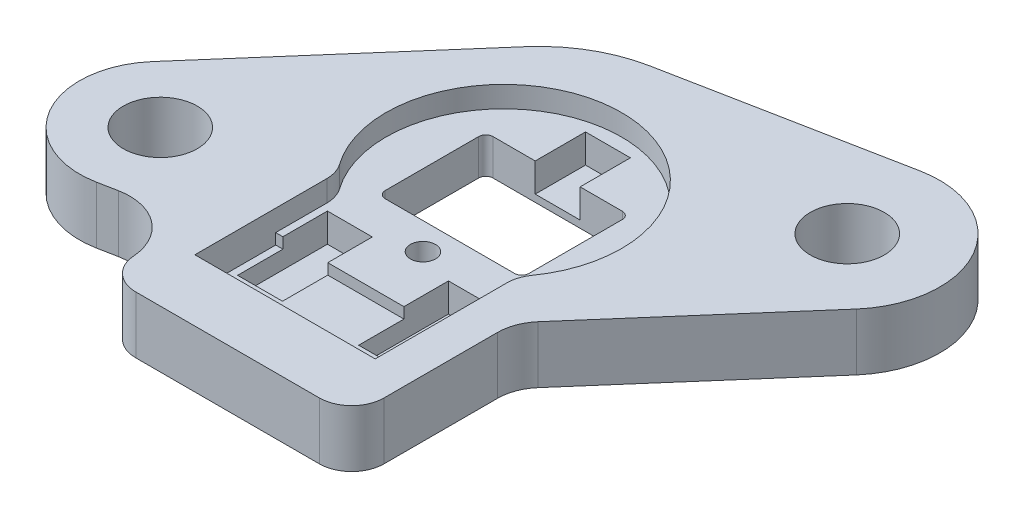
from build123d import *

# Parameters (mm, degrees)
BOSS_EXTRUDE1_DEPTH            = 4.0386
SKETCH2_R                      = 4.7625
BOSS_EXTRUDE2_DEPTH            = 0.508
SKETCH3_R                      = 4.7625
BOSS_EXTRUDE3_DEPTH            = 0.508
CUT_EXTRUDE1_DEPTH             = 1.4986
SKETCH5_W                      = 12.7508
SKETCH5_H                      = 5.715
CUT_EXTRUDE2_DEPTH             = 0.762
SKETCH6_W                      = 3.175
SKETCH6_H                      = 3.2004
CUT_EXTRUDE3_DEPTH             = 1.27
SKETCH7_W                      = 3.175
SKETCH7_H                      = 3.2004
CUT_EXTRUDE4_DEPTH             = 1.27
SKETCH8_W                      = 3.175
SKETCH8_H                      = 2.032
CUT_EXTRUDE5_DEPTH             = 3.1496
SKETCH9_W                      = 3.175
SKETCH9_H                      = 2.032
CUT_EXTRUDE6_DEPTH             = 3.1496
SKETCH10_W                     = 10.16
SKETCH10_H                     = 7.62
CUT_EXTRUDE7_DEPTH             = 5.0386
SKETCH11_W                     = 3.175
SKETCH11_H                     = 2.032
CUT_EXTRUDE8_DEPTH             = 3.556
F_10_CLEARANCE_HOLE1_D         = 5.2324
F_10_CLEARANCE_HOLE1_DEPTH     = 4.5466
F_50_0_07_DIAMETER_HOLE1_D     = 1.778
F_50_0_07_DIAMETER_HOLE1_DEPTH = 3.048
FILLET1_R                      = 0.508
FILLET3_R                      = 2.286
FILLET4_R                      = 3.175
FILLET5_R                      = 9.9187


with BuildPart() as part:
    # Sketch1 → Boss-Extrude1 (new body)
    with BuildSketch(Plane(origin=(0, 2.0193, 0), x_dir=(1, 0, 0), z_dir=(0, 1, 0))):
        with BuildLine():
            Line((-8.93437079, -19.83232), (9.077817244, -19.83232))
            Line((9.077817244, -19.83232), (9.077817244, -8.327843243))
            Line((9.077817244, -8.327843243), (20.330239386, 4.595371256))
            ThreePointArc((20.330239386, 4.595371256), (21.061730892, 12.159996), (14.144827941, 15.308818145))
            Line((14.144827941, 15.308818145), (-5.192523198, 11.533713998))
            Line((-5.192523198, 11.533713998), (-19.708049879, -5.137120292))
            ThreePointArc((-19.708049879, -5.137120292), (-20.347266862, -11.7475), (-14.302901614, -14.499111708))
            Line((-14.302901614, -14.499111708), (-12.995647781, -14.243905122))
            ThreePointArc((-12.995647781, -14.243905122), (-9.183549937, -15.74346998), (-8.93437079, -19.83232))
        make_face()
    extrude(amount=-BOSS_EXTRUDE1_DEPTH)

    # Sketch2 → Boss-Extrude2 (add)
    with BuildSketch(Plane.XZ.offset(2.0193)):
        with Locations((15.397931679, -8.89)):
            Circle(SKETCH2_R)
    extrude(amount=BOSS_EXTRUDE2_DEPTH)

    # Sketch3 → Boss-Extrude3 (add)
    with BuildSketch(Plane.XZ.offset(2.0193)):
        with Locations((-15.397931679, 8.89)):
            Circle(SKETCH3_R)
    extrude(amount=BOSS_EXTRUDE3_DEPTH)

    # Sketch4 → Cut-Extrude1 (cut)
    with BuildSketch(Plane(origin=(0, 2.0193, 0), x_dir=(-1, 0, 0), z_dir=(0, 1, 0))):
        with BuildLine():
            Line((6.3754, 5.363130455), (6.3754, 15.4686))
            Line((6.3754, 15.4686), (-6.3754, 15.4686))
            Line((-6.3754, 15.4686), (-6.3754, 5.363130455))
            ThreePointArc((-6.3754, 5.363130455), (0, -8.3312), (6.3754, 5.363130455))
        make_face()
    extrude(amount=-CUT_EXTRUDE1_DEPTH, mode=Mode.SUBTRACT)

    # Sketch5 → Cut-Extrude2 (cut)
    with BuildSketch(Plane(origin=(0, 0.5207, 0), x_dir=(-1, 0, 0), z_dir=(0, 1, 0))):
        with Locations((0, 12.6111)):
            Rectangle(SKETCH5_W, SKETCH5_H)
    extrude(amount=-CUT_EXTRUDE2_DEPTH, mode=Mode.SUBTRACT)

    # Sketch6 → Cut-Extrude3 (cut)
    with BuildSketch(Plane(origin=(0, -0.2413, 0), x_dir=(-1, 0, 0), z_dir=(0, 1, 0))):
        with Locations((4.2799, 11.3538)):
            Rectangle(SKETCH6_W, SKETCH6_H)
    extrude(amount=-CUT_EXTRUDE3_DEPTH, mode=Mode.SUBTRACT)

    # Sketch7 → Cut-Extrude4 (cut)
    with BuildSketch(Plane(origin=(0, -0.2413, 0), x_dir=(-1, 0, 0), z_dir=(0, 1, 0))):
        with Locations((-4.2799, 11.3538)):
            Rectangle(SKETCH7_W, SKETCH7_H)
    extrude(amount=-CUT_EXTRUDE4_DEPTH, mode=Mode.SUBTRACT)

    # Sketch8 → Cut-Extrude5 (cut)
    with BuildSketch(Plane.XY.offset(9.7536)):
        with Locations((4.2799, -0.4953)):
            Rectangle(SKETCH8_W, SKETCH8_H)
    extrude(amount=-CUT_EXTRUDE5_DEPTH, mode=Mode.SUBTRACT)

    # Sketch9 → Cut-Extrude6 (cut)
    with BuildSketch(Plane.XY.offset(9.7536)):
        with Locations((-4.2799, -0.4953)):
            Rectangle(SKETCH9_W, SKETCH9_H)
    extrude(amount=-CUT_EXTRUDE6_DEPTH, mode=Mode.SUBTRACT)

    # Sketch10 → Cut-Extrude7 (cut, through all)
    with BuildSketch(Plane.XZ.offset(2.0193)):
        Rectangle(SKETCH10_W, SKETCH10_H)
    extrude(amount=-CUT_EXTRUDE7_DEPTH, mode=Mode.SUBTRACT)

    # Sketch11 → Cut-Extrude8 (cut)
    with BuildSketch(Plane.XY.offset(-3.81)):
        with Locations((0, -0.4953)):
            Rectangle(SKETCH11_W, SKETCH11_H)
    extrude(amount=-CUT_EXTRUDE8_DEPTH, mode=Mode.SUBTRACT)

    # #10 Clearance Hole1
    with Locations(Plane(origin=(0, -2.5273, 0), x_dir=(-1, 0, 0), z_dir=(0, -1, 0))):
        with Locations((15.397931679, -8.89), (-15.397931679, 8.89)):
            Hole(F_10_CLEARANCE_HOLE1_D / 2, depth=F_10_CLEARANCE_HOLE1_DEPTH)

    # #50 (0.07) Diameter Hole1
    with Locations(Plane(origin=(0, 0.5207, 0), x_dir=(1, 0, 0), z_dir=(0, 1, 0))):
        with Locations((0, -5.715)):
            Hole(F_50_0_07_DIAMETER_HOLE1_D / 2, depth=F_50_0_07_DIAMETER_HOLE1_DEPTH)

    # Fillet1
    fillet1_edges = [part.edges().sort_by_distance(p)[0] for p in [
        (-5.08, -0.7493, 3.81),
        (5.08, -0.7493, 3.81),
        (5.08, -0.7493, -3.81),
        (-5.08, -0.7493, -3.81),
    ]]
    fillet(fillet1_edges, radius=FILLET1_R)

    # Fillet3
    fillet3_edges = [part.edges().sort_by_distance(p)[0] for p in [
        (9.077817244, 0, 19.83232),
        (-8.93437079, 0, 19.83232),
        (-6.3754, 1.27, 5.363130455),
        (6.3754, 1.27, 5.363130455),
    ]]
    fillet(fillet3_edges, radius=FILLET3_R)

    # Fillet4
    fillet4_edges = [part.edges().sort_by_distance(p)[0] for p in [
        (9.077817244, 0, 8.327843243),
    ]]
    fillet(fillet4_edges, radius=FILLET4_R)

    # Fillet5
    fillet5_edges = [part.edges().sort_by_distance(p)[0] for p in [
        (-5.192523198, 0, -11.533713998),
    ]]
    fillet(fillet5_edges, radius=FILLET5_R)


solid = part.part
